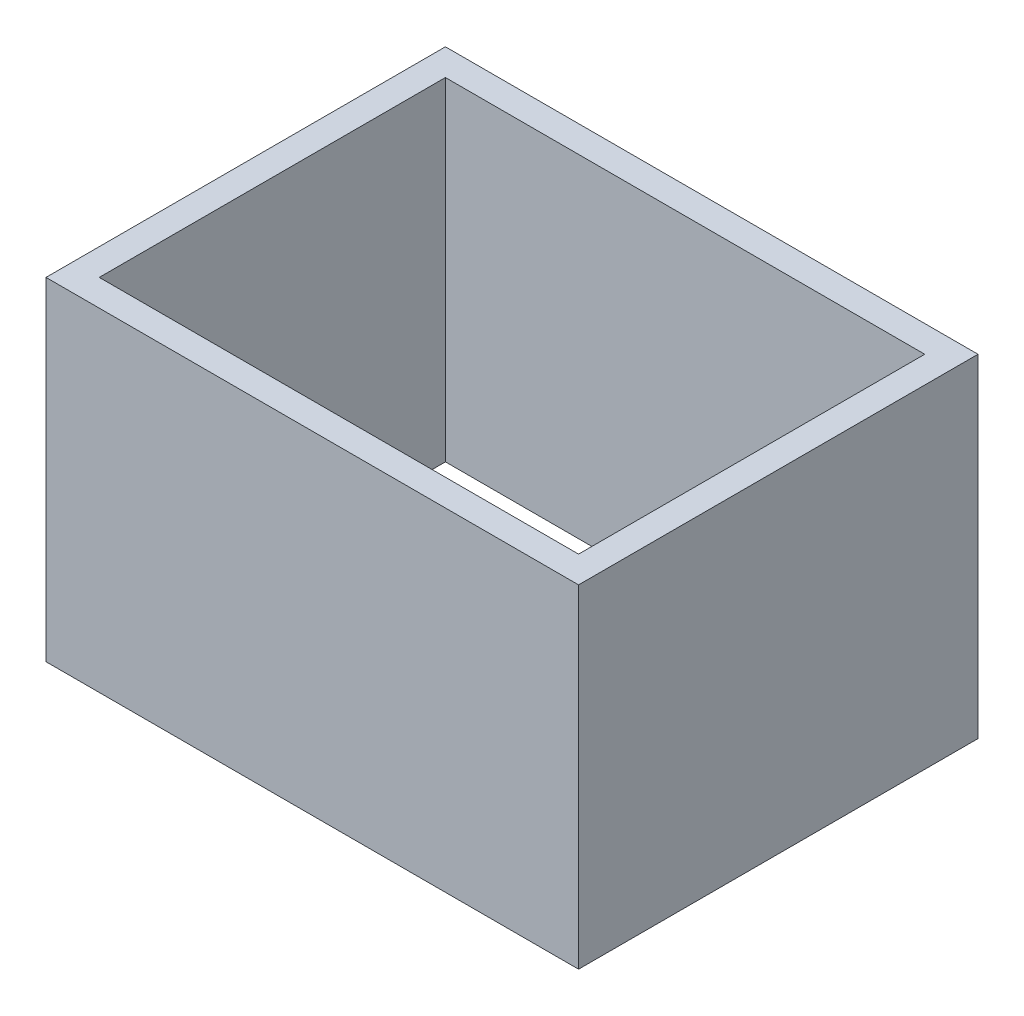
from build123d import *

# Parameters (mm, degrees)
SKIZZE2_W                       = 4000
SKIZZE2_H                       = 3000
SKIZZE2_W_2                     = 3600
SKIZZE2_H_2                     = 2600
AUFSATZ_LINEAR_AUSTRAGEN1_DEPTH = 2500


with BuildPart() as part:
    # Skizze2 → Aufsatz-Linear austragen1 (new body)
    with BuildSketch(Plane(origin=(0, 0, 0), x_dir=(1, 0, 0), z_dir=(0, 1, 0))):
        with Locations((2000, 1500)):
            Rectangle(SKIZZE2_W, SKIZZE2_H)
        with Locations((2000, 1500)):
            Rectangle(SKIZZE2_W_2, SKIZZE2_H_2, mode=Mode.SUBTRACT)
    extrude(amount=AUFSATZ_LINEAR_AUSTRAGEN1_DEPTH)


solid = part.part
